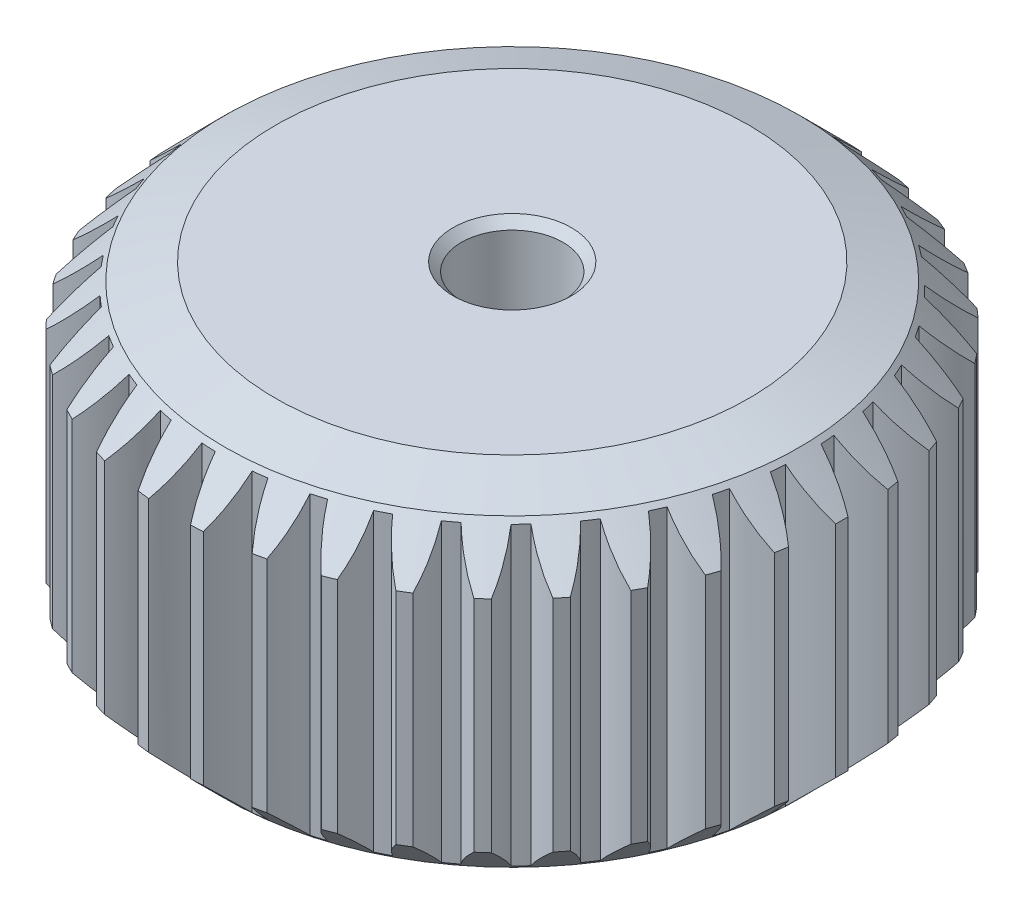
from build123d import *

# Parameters (mm, degrees)
EXTRUDE_1_DEPTH          = 20
EXTRUDE_1_2_DEPTH        = 20
EXTRUDE_1_3_DEPTH        = 20
EXTRUDE_1_4_DEPTH        = 20
EXTRUDE_1_5_DEPTH        = 20
EXTRUDE_1_6_DEPTH        = 20
EXTRUDE_1_7_DEPTH        = 20
EXTRUDE_1_8_DEPTH        = 20
EXTRUDE_1_9_DEPTH        = 20
EXTRUDE_1_10_DEPTH       = 20
EXTRUDE_1_11_DEPTH       = 20
EXTRUDE_1_12_DEPTH       = 20
EXTRUDE_1_13_DEPTH       = 20
EXTRUDE_1_14_DEPTH       = 20
EXTRUDE_1_15_DEPTH       = 20
EXTRUDE_1_16_DEPTH       = 20
EXTRUDE_1_17_DEPTH       = 20
EXTRUDE_1_18_DEPTH       = 20
EXTRUDE_1_19_DEPTH       = 20
EXTRUDE_1_20_DEPTH       = 20
EXTRUDE_1_21_DEPTH       = 20
EXTRUDE_1_22_DEPTH       = 20
EXTRUDE_1_23_DEPTH       = 20
EXTRUDE_1_24_DEPTH       = 20
EXTRUDE_1_25_DEPTH       = 20
EXTRUDE_1_26_DEPTH       = 20
EXTRUDE_1_27_DEPTH       = 20
EXTRUDE_1_28_DEPTH       = 20
EXTRUDE_1_29_DEPTH       = 20
EXTRUDE_1_30_DEPTH       = 20
EXTRUDE_1_31_DEPTH       = 20
EXTRUDE_1_32_DEPTH       = 20
EXTRUDE_1_33_DEPTH       = 20
EXTRUDE_1_34_DEPTH       = 20
EXTRUDE_1_35_DEPTH       = 20
EXTRUDE_1_36_DEPTH       = 20
EXTRUDE_1_37_DEPTH       = 20
SKETCH_2_R               = 17.25
EXTRUDE_2_DEPTH          = 20
SKETCH_3_R               = 3
CUT_EXTRUDE_1_DEPTH      = 1
CUT_EXTRUDE_1_DEPTH_BACK = 21
CHAMFER_1_SIZE           = 0.5


with BuildPart() as part:
    # 草图1 → 凸台-拉伸1 (new body)
    with BuildSketch(Plane(origin=(0, 0, 0), x_dir=(1, 0, 0), z_dir=(0, 1, 0))):
        with BuildLine():
            ThreePointArc((0.463179131, 19.494498329), (-0.032777448, 18.407729398), (-0.315632772, 17.247112105))
            ThreePointArc((-0.315632772, 17.247112105), (0.732110755, 17.234457167), (1.777152988, 17.158211657))
            ThreePointArc((1.777152988, 17.158211657), (1.593743876, 18.338635621), (1.19173843, 19.46354951))
            ThreePointArc((1.19173843, 19.46354951), (0.827603462, 19.482429841), (0.463179131, 19.494498329))
        make_face()
    extrude(amount=EXTRUDE_1_DEPTH)



with BuildPart() as body_2:
    # 草图1 → Extrude 1 2 (new body)
    with BuildSketch(Plane(origin=(0, 0, 0), x_dir=(1, 0, 0), z_dir=(0, 1, 0))):
        with BuildLine():
            ThreePointArc((2.603683412, 17.052370295), (3.634217407, 16.862827872), (4.651342106, 16.611066089))
            ThreePointArc((4.651342106, 16.611066089), (4.670063785, 17.805507019), (4.463952191, 18.982179296))
            ThreePointArc((4.463952191, 18.982179296), (4.108245765, 19.062327159), (3.751102931, 19.135810064))
            ThreePointArc((3.751102931, 19.135810064), (3.078615394, 18.148490384), (2.603683412, 17.052370295))
        make_face()
    extrude(amount=EXTRUDE_1_2_DEPTH)


with BuildPart() as body_3:
    # 草图1 → Extrude 1 3 (new body)
    with BuildSketch(Plane(origin=(0, 0, 0), x_dir=(1, 0, 0), z_dir=(0, 1, 0))):
        with BuildLine():
            ThreePointArc((5.448096364, 16.36706284), (6.431774242, 16.006085721), (7.391720579, 15.586050394))
            ThreePointArc((7.391720579, 15.586050394), (7.612034461, 16.760146399), (7.607746175, 17.954726345))
            ThreePointArc((7.607746175, 17.954726345), (7.270701317, 18.093836032), (6.931114328, 18.226619384))
            ThreePointArc((6.931114328, 18.226619384), (6.101442077, 17.367152344), (5.448096364, 16.36706284))
        make_face()
    extrude(amount=EXTRUDE_1_3_DEPTH)


with BuildPart() as body_4:
    # 草图1 → Extrude 1 4 (new body)
    with BuildSketch(Plane(origin=(0, 0, 0), x_dir=(1, 0, 0), z_dir=(0, 1, 0))):
        with BuildLine():
            ThreePointArc((8.135777504, 15.210904786), (9.044300641, 14.688877626), (9.91945271, 14.112652406))
            ThreePointArc((9.91945271, 14.112652406), (10.335020765, 15.232626883), (10.532679153, 16.410748608))
            ThreePointArc((10.532679153, 16.410748608), (10.223992029, 16.604818186), (9.911730186, 16.79308205))
            ThreePointArc((9.911730186, 16.79308205), (8.94874138, 16.086192952), (8.135777504, 15.210904786))
        make_face()
    extrude(amount=EXTRUDE_1_4_DEPTH)


with BuildPart() as body_5:
    # 草图1 → Extrude 1 5 (new body)
    with BuildSketch(Plane(origin=(0, 0, 0), x_dir=(1, 0, 0), z_dir=(0, 1, 0))):
        with BuildLine():
            ThreePointArc((10.589407138, 13.617156696), (11.396638978, 12.949097266), (12.161820246, 12.233259104))
            ThreePointArc((12.161820246, 12.233259104), (12.760687339, 13.266892425), (13.154606128, 14.394663511))
            ThreePointArc((13.154606128, 14.394663511), (12.883157106, 14.638109952), (12.607203612, 14.87643832))
            ThreePointArc((12.607203612, 14.87643832), (11.538601686, 14.342463076), (10.589407138, 13.617156696))
        make_face()
    extrude(amount=EXTRUDE_1_5_DEPTH)


with BuildPart() as body_6:
    # 草图1 → Extrude 1 6 (new body)
    with BuildSketch(Plane(origin=(0, 0, 0), x_dir=(1, 0, 0), z_dir=(0, 1, 0))):
        with BuildLine():
            ThreePointArc((12.738398808, 11.6316678), (13.421116762, 10.836794953), (14.054314357, 10.00193721))
            ThreePointArc((14.054314357, 10.00193721), (14.819252171, 10.919493627), (15.398099036, 11.964470154))
            ThreePointArc((15.398099036, 11.964470154), (15.171697209, 12.250289947), (14.939990745, 12.531826545))
            ThreePointArc((14.939990745, 12.531826545), (13.796517431, 12.186126651), (12.738398808, 11.6316678))
        make_face()
    extrude(amount=EXTRUDE_1_6_DEPTH)


with BuildPart() as body_7:
    # 草图1 → Extrude 1 7 (new body)
    with BuildSketch(Plane(origin=(0, 0, 0), x_dir=(1, 0, 0), z_dir=(0, 1, 0))):
        with BuildLine():
            ThreePointArc((14.520929937, 9.311556999), (15.059493452, 8.412737781), (15.542491433, 7.482877793))
            ThreePointArc((15.542491433, 7.482877793), (16.4514941, 8.257960878), (17.19861667, 9.190080774))
            ThreePointArc((17.19861667, 9.190080774), (17.023775207, 9.510051404), (16.842981545, 9.826696937))
            ThreePointArc((16.842981545, 9.826696937), (15.657532487, 9.679217549), (14.520929937, 9.311556999))
        make_face()
    extrude(amount=EXTRUDE_1_7_DEPTH)


with BuildPart() as body_8:
    # 草图1 → Extrude 1 8 (new body)
    with BuildSketch(Plane(origin=(0, 0, 0), x_dir=(1, 0, 0), z_dir=(0, 1, 0))):
        with BuildLine():
            ThreePointArc((15.885720351, 6.723569657), (16.264635934, 5.746661459), (16.583539328, 4.748549606))
            ThreePointArc((16.583539328, 4.748549606), (17.610456496, 5.35886163), (18.504361416, 6.151309503))
            ThreePointArc((18.504361416, 6.151309503), (18.386110186, 6.496225997), (18.261430431, 6.838871149))
            ThreePointArc((18.261430431, 6.838871149), (17.068108842, 6.893854982), (15.885720351, 6.723569657))
        make_face()
    extrude(amount=EXTRUDE_1_8_DEPTH)


with BuildPart() as body_9:
    # 草图1 → Extrude 1 9 (new body)
    with BuildSketch(Plane(origin=(0, 0, 0), x_dir=(1, 0, 0), z_dir=(0, 1, 0))):
        with BuildLine():
            ThreePointArc((16.793507513, 3.942157458), (17.001874453, 2.915264151), (17.14750899, 1.877614292))
            ThreePointArc((17.14750899, 1.877614292), (18.262798122, 2.30559769), (19.277769374, 2.935576257))
            ThreePointArc((19.277769374, 2.935576257), (19.219510252, 3.295515996), (19.154531213, 3.65430349))
            ThreePointArc((19.154531213, 3.65430349), (17.987666782, 3.910168758), (16.793507513, 3.942157458))
        make_face()
    extrude(amount=EXTRUDE_1_9_DEPTH)


with BuildPart() as body_10:
    # 草图1 → Extrude 1 10 (new body)
    with BuildSketch(Plane(origin=(0, 0, 0), x_dir=(1, 0, 0), z_dir=(0, 1, 0))):
        with BuildLine():
            ThreePointArc((17.218176039, 1.047336566), (17.25, 0), (17.218176039, -1.047336566))
            ThreePointArc((17.218176039, -1.047336566), (18.389752298, -0.813994098), (19.496591007, -0.364608173))
            ThreePointArc((19.496591007, -0.364608173), (19.5, 0), (19.496591007, 0.364608173))
            ThreePointArc((19.496591007, 0.364608173), (18.389752298, 0.813994098), (17.218176039, 1.047336566))
        make_face()
    extrude(amount=EXTRUDE_1_10_DEPTH)


with BuildPart() as body_11:
    # 草图1 → Extrude 1 11 (new body)
    with BuildSketch(Plane(origin=(0, 0, 0), x_dir=(1, 0, 0), z_dir=(0, 1, 0))):
        with BuildLine():
            ThreePointArc((17.14750899, -1.877614292), (17.001874453, -2.915264151), (16.793507513, -3.942157458))
            ThreePointArc((16.793507513, -3.942157458), (17.987666782, -3.910168758), (19.154531213, -3.65430349))
            ThreePointArc((19.154531213, -3.65430349), (19.219510252, -3.295515996), (19.277769374, -2.935576257))
            ThreePointArc((19.277769374, -2.935576257), (18.262798122, -2.30559769), (17.14750899, -1.877614292))
        make_face()
    extrude(amount=EXTRUDE_1_11_DEPTH)


with BuildPart() as body_12:
    # 草图1 → Extrude 1 12 (new body)
    with BuildSketch(Plane(origin=(0, 0, 0), x_dir=(1, 0, 0), z_dir=(0, 1, 0))):
        with BuildLine():
            ThreePointArc((16.583539328, -4.748549606), (16.264635934, -5.746661459), (15.885720351, -6.723569657))
            ThreePointArc((15.885720351, -6.723569657), (17.068108842, -6.893854982), (18.261430431, -6.838871149))
            ThreePointArc((18.261430431, -6.838871149), (18.386110186, -6.496225997), (18.504361416, -6.151309503))
            ThreePointArc((18.504361416, -6.151309503), (17.610456496, -5.35886163), (16.583539328, -4.748549606))
        make_face()
    extrude(amount=EXTRUDE_1_12_DEPTH)


with BuildPart() as body_13:
    # 草图1 → Extrude 1 13 (new body)
    with BuildSketch(Plane(origin=(0, 0, 0), x_dir=(1, 0, 0), z_dir=(0, 1, 0))):
        with BuildLine():
            ThreePointArc((15.542491433, -7.482877793), (15.059493452, -8.412737781), (14.520929937, -9.311556999))
            ThreePointArc((14.520929937, -9.311556999), (15.657532487, -9.679217549), (16.842981545, -9.826696937))
            ThreePointArc((16.842981545, -9.826696937), (17.023775207, -9.510051404), (17.19861667, -9.190080774))
            ThreePointArc((17.19861667, -9.190080774), (16.4514941, -8.257960878), (15.542491433, -7.482877793))
        make_face()
    extrude(amount=EXTRUDE_1_13_DEPTH)


with BuildPart() as body_14:
    # 草图1 → Extrude 1 14 (new body)
    with BuildSketch(Plane(origin=(0, 0, 0), x_dir=(1, 0, 0), z_dir=(0, 1, 0))):
        with BuildLine():
            ThreePointArc((14.054314357, -10.00193721), (13.421116762, -10.836794953), (12.738398808, -11.6316678))
            ThreePointArc((12.738398808, -11.6316678), (13.796517431, -12.186126651), (14.939990745, -12.531826545))
            ThreePointArc((14.939990745, -12.531826545), (15.171697209, -12.250289947), (15.398099036, -11.964470154))
            ThreePointArc((15.398099036, -11.964470154), (14.819252171, -10.919493627), (14.054314357, -10.00193721))
        make_face()
    extrude(amount=EXTRUDE_1_14_DEPTH)


with BuildPart() as body_15:
    # 草图1 → Extrude 1 15 (new body)
    with BuildSketch(Plane(origin=(0, 0, 0), x_dir=(1, 0, 0), z_dir=(0, 1, 0))):
        with BuildLine():
            ThreePointArc((12.161820246, -12.233259104), (11.396638978, -12.949097266), (10.589407138, -13.617156696))
            ThreePointArc((10.589407138, -13.617156696), (11.538601686, -14.342463076), (12.607203612, -14.87643832))
            ThreePointArc((12.607203612, -14.87643832), (12.883157106, -14.638109952), (13.154606128, -14.394663511))
            ThreePointArc((13.154606128, -14.394663511), (12.760687339, -13.266892425), (12.161820246, -12.233259104))
        make_face()
    extrude(amount=EXTRUDE_1_15_DEPTH)


with BuildPart() as body_16:
    # 草图1 → Extrude 1 16 (new body)
    with BuildSketch(Plane(origin=(0, 0, 0), x_dir=(1, 0, 0), z_dir=(0, 1, 0))):
        with BuildLine():
            ThreePointArc((9.91945271, -14.112652406), (9.044300641, -14.688877626), (8.135777504, -15.210904786))
            ThreePointArc((8.135777504, -15.210904786), (8.94874138, -16.086192952), (9.911730186, -16.79308205))
            ThreePointArc((9.911730186, -16.79308205), (10.223992029, -16.604818186), (10.532679153, -16.410748608))
            ThreePointArc((10.532679153, -16.410748608), (10.335020765, -15.232626883), (9.91945271, -14.112652406))
        make_face()
    extrude(amount=EXTRUDE_1_16_DEPTH)


with BuildPart() as body_17:
    # 草图1 → Extrude 1 17 (new body)
    with BuildSketch(Plane(origin=(0, 0, 0), x_dir=(1, 0, 0), z_dir=(0, 1, 0))):
        with BuildLine():
            ThreePointArc((7.391720579, -15.586050394), (6.431774242, -16.006085721), (5.448096364, -16.36706284))
            ThreePointArc((5.448096364, -16.36706284), (6.101442077, -17.367152344), (6.931114328, -18.226619384))
            ThreePointArc((6.931114328, -18.226619384), (7.270701317, -18.093836032), (7.607746175, -17.954726345))
            ThreePointArc((7.607746175, -17.954726345), (7.612034461, -16.760146399), (7.391720579, -15.586050394))
        make_face()
    extrude(amount=EXTRUDE_1_17_DEPTH)


with BuildPart() as body_18:
    # 草图1 → Extrude 1 18 (new body)
    with BuildSketch(Plane(origin=(0, 0, 0), x_dir=(1, 0, 0), z_dir=(0, 1, 0))):
        with BuildLine():
            ThreePointArc((4.651342106, -16.611066089), (3.634217407, -16.862827872), (2.603683412, -17.052370295))
            ThreePointArc((2.603683412, -17.052370295), (3.078615394, -18.148490384), (3.751102931, -19.135810064))
            ThreePointArc((3.751102931, -19.135810064), (4.108245765, -19.062327159), (4.463952191, -18.982179296))
            ThreePointArc((4.463952191, -18.982179296), (4.670063785, -17.805507019), (4.651342106, -16.611066089))
        make_face()
    extrude(amount=EXTRUDE_1_18_DEPTH)


with BuildPart() as body_19:
    # 草图1 → Extrude 1 19 (new body)
    with BuildSketch(Plane(origin=(0, 0, 0), x_dir=(1, 0, 0), z_dir=(0, 1, 0))):
        with BuildLine():
            ThreePointArc((1.777152988, -17.158211657), (0.732110755, -17.234457167), (-0.315632772, -17.247112105))
            ThreePointArc((-0.315632772, -17.247112105), (-0.032777448, -18.407729398), (0.463179131, -19.494498329))
            ThreePointArc((0.463179131, -19.494498329), (0.827603462, -19.482429841), (1.19173843, -19.46354951))
            ThreePointArc((1.19173843, -19.46354951), (1.593743876, -18.338635621), (1.777152988, -17.158211657))
        make_face()
    extrude(amount=EXTRUDE_1_19_DEPTH)


with BuildPart() as body_20:
    # 草图1 → Extrude 1 20 (new body)
    with BuildSketch(Plane(origin=(0, 0, 0), x_dir=(1, 0, 0), z_dir=(0, 1, 0))):
        with BuildLine():
            ThreePointArc((-1.148161585, -17.211746715), (-2.191057391, -17.110282508), (-3.225868776, -16.945685901))
            ThreePointArc((-3.225868776, -16.945685901), (-3.143227343, -18.137411553), (-2.838069488, -19.29236537))
            ThreePointArc((-2.838069488, -19.29236537), (-2.476847485, -19.342058488), (-2.114759476, -19.384988841))
            ThreePointArc((-2.114759476, -19.384988841), (-1.528425142, -18.344195064), (-1.148161585, -17.211746715))
        make_face()
    extrude(amount=EXTRUDE_1_20_DEPTH)


with BuildPart() as body_21:
    # 草图1 → Extrude 1 21 (new body)
    with BuildSketch(Plane(origin=(0, 0, 0), x_dir=(1, 0, 0), z_dir=(0, 1, 0))):
        with BuildLine():
            ThreePointArc((-4.04044564, -16.770131157), (-5.051192805, -16.493876174), (-6.043302409, -16.156763166))
            ThreePointArc((-6.043302409, -16.156763166), (-6.16325231, -17.3453134), (-6.057672016, -18.535226186))
            ThreePointArc((-6.057672016, -18.535226186), (-5.71004404, -18.645251327), (-5.360419602, -18.748757337))
            ThreePointArc((-5.360419602, -18.748757337), (-4.606624152, -17.822025415), (-4.04044564, -16.770131157))
        make_face()
    extrude(amount=EXTRUDE_1_21_DEPTH)


with BuildPart() as body_22:
    # 草图1 → Extrude 1 22 (new body)
    with BuildSketch(Plane(origin=(0, 0, 0), x_dir=(1, 0, 0), z_dir=(0, 1, 0))):
        with BuildLine():
            ThreePointArc((-6.81649343, -15.84606946), (-7.766014598, -15.402971053), (-8.686881234, -14.903039772))
            ThreePointArc((-8.686881234, -14.903039772), (-9.00597173, -16.05422216), (-9.103006348, -17.244862291))
            ThreePointArc((-9.103006348, -17.244862291), (-8.778973024, -17.412054234), (-8.451870216, -17.573158221))
            ThreePointArc((-8.451870216, -17.573158221), (-7.552298972, -16.787148543), (-6.81649343, -15.84606946))
        make_face()
    extrude(amount=EXTRUDE_1_22_DEPTH)


with BuildPart() as body_23:
    # 草图1 → Extrude 1 23 (new body)
    with BuildSketch(Plane(origin=(0, 0, 0), x_dir=(1, 0, 0), z_dir=(0, 1, 0))):
        with BuildLine():
            ThreePointArc((-9.396443115, -14.466145195), (-10.257422291, -13.868950499), (-11.080554302, -13.220583057))
            ThreePointArc((-11.080554302, -13.220583057), (-11.589605739, -14.301280179), (-11.886463762, -15.458395105))
            ThreePointArc((-11.886463762, -15.458395105), (-11.595346938, -15.677944042), (-11.300175912, -15.892011338))
            ThreePointArc((-11.300175912, -15.892011338), (-10.280707901, -15.269335972), (-9.396443115, -14.466145195))
        make_face()
    extrude(amount=EXTRUDE_1_23_DEPTH)


with BuildPart() as body_24:
    # 草图1 → Extrude 1 24 (new body)
    with BuildSketch(Plane(origin=(0, 0, 0), x_dir=(1, 0, 0), z_dir=(0, 1, 0))):
        with BuildLine():
            ThreePointArc((-11.706074239, -12.670056271), (-12.453742621, -11.93594549), (-13.155459997, -11.157794238))
            ThreePointArc((-13.155459997, -11.157794238), (-13.839827893, -12.136916406), (-14.327969256, -13.227218037))
            ThreePointArc((-14.327969256, -13.227218037), (-14.078143832, -13.492807945), (-13.823396121, -13.753680223))
            ThreePointArc((-13.823396121, -13.753680223), (-12.713359582, -13.312252405), (-11.706074239, -12.670056271))
        make_face()
    extrude(amount=EXTRUDE_1_24_DEPTH)


with BuildPart() as body_25:
    # 草图1 → Extrude 1 25 (new body)
    with BuildSketch(Plane(origin=(0, 0, 0), x_dir=(1, 0, 0), z_dir=(0, 1, 0))):
        with BuildLine():
            ThreePointArc((-13.678942921, -10.509472896), (-14.291791449, -9.659565061), (-14.85190706, -8.774015994))
            ThreePointArc((-14.85190706, -8.774015994), (-15.691903397, -9.623395645), (-16.35728516, -10.61551799))
            ThreePointArc((-16.35728516, -10.61551799), (-16.15593816, -10.91950833), (-15.948942392, -11.219680769))
            ThreePointArc((-15.948942392, -11.219680769), (-14.780271055, -10.972199575), (-13.678942921, -10.509472896))
        make_face()
    extrude(amount=EXTRUDE_1_25_DEPTH)


with BuildPart() as body_26:
    # 草图1 → Extrude 1 26 (new body)
    with BuildSketch(Plane(origin=(0, 0, 0), x_dir=(1, 0, 0), z_dir=(0, 1, 0))):
        with BuildLine():
            ThreePointArc((-15.258293321, -8.046551121), (-15.718691459, -7.105296532), (-16.121091798, -6.137825285))
            ThreePointArc((-16.121091798, -6.137825285), (-17.09255141, -6.833027313), (-17.916031752, -7.698428817))
            ThreePointArc((-17.916031752, -7.698428817), (-17.768955563, -8.032074341), (-17.615666629, -8.362911528))
            ThreePointArc((-17.615666629, -8.362911528), (-16.42198104, -8.31649654), (-15.258293321, -8.046551121))
        make_face()
    extrude(amount=EXTRUDE_1_26_DEPTH)


with BuildPart() as body_27:
    # 草图1 → Extrude 1 27 (new body)
    with BuildSketch(Plane(origin=(0, 0, 0), x_dir=(1, 0, 0), z_dir=(0, 1, 0))):
        with BuildLine():
            ThreePointArc((-16.398690402, -5.35214472), (-16.693393335, -4.346621559), (-16.926502077, -3.325060518))
            ThreePointArc((-16.926502077, -3.325060518), (-18.001477839, -3.846085226), (-18.959366731, -4.559869863))
            ThreePointArc((-18.959366731, -4.559869863), (-18.870792465, -4.913572197), (-18.775620209, -5.265556548))
            ThreePointArc((-18.775620209, -5.265556548), (-17.59126053, -5.421543041), (-16.398690402, -5.35214472))
        make_face()
    extrude(amount=EXTRUDE_1_27_DEPTH)


with BuildPart() as body_28:
    # 草图1 → Extrude 1 28 (new body)
    with BuildSketch(Plane(origin=(0, 0, 0), x_dir=(1, 0, 0), z_dir=(0, 1, 0))):
        with BuildLine():
            ThreePointArc((-17.067327017, -2.503766861), (-17.187856677, -1.462902197), (-17.244967708, -0.416639813))
            ThreePointArc((-17.244967708, -0.416639813), (-18.392534526, -0.748498269), (-19.457275247, -1.290131756))
            ThreePointArc((-19.457275247, -1.290131756), (-19.429751027, -1.653715527), (-19.395433381, -2.016721093))
            ThreePointArc((-19.395433381, -2.016721093), (-18.254471482, -2.37062162), (-17.067327017, -2.503766861))
        make_face()
    extrude(amount=EXTRUDE_1_28_DEPTH)


with BuildPart() as body_29:
    # 草图1 → Extrude 1 29 (new body)
    with BuildSketch(Plane(origin=(0, 0, 0), x_dir=(1, 0, 0), z_dir=(0, 1, 0))):
        with BuildLine():
            ThreePointArc((-17.244967708, 0.416639813), (-17.187856677, 1.462902197), (-17.067327017, 2.503766861))
            ThreePointArc((-17.067327017, 2.503766861), (-18.254471482, 2.37062162), (-19.395433381, 2.016721093))
            ThreePointArc((-19.395433381, 2.016721093), (-19.429751027, 1.653715527), (-19.457275247, 1.290131756))
            ThreePointArc((-19.457275247, 1.290131756), (-18.392534526, 0.748498269), (-17.244967708, 0.416639813))
        make_face()
    extrude(amount=EXTRUDE_1_29_DEPTH)


with BuildPart() as body_30:
    # 草图1 → Extrude 1 30 (new body)
    with BuildSketch(Plane(origin=(0, 0, 0), x_dir=(1, 0, 0), z_dir=(0, 1, 0))):
        with BuildLine():
            ThreePointArc((-16.926502077, 3.325060518), (-16.693393335, 4.346621559), (-16.398690402, 5.35214472))
            ThreePointArc((-16.398690402, 5.35214472), (-17.59126053, 5.421543041), (-18.775620209, 5.265556548))
            ThreePointArc((-18.775620209, 5.265556548), (-18.870792465, 4.913572197), (-18.959366731, 4.559869863))
            ThreePointArc((-18.959366731, 4.559869863), (-18.001477839, 3.846085226), (-16.926502077, 3.325060518))
        make_face()
    extrude(amount=EXTRUDE_1_30_DEPTH)


with BuildPart() as body_31:
    # 草图1 → Extrude 1 31 (new body)
    with BuildSketch(Plane(origin=(0, 0, 0), x_dir=(1, 0, 0), z_dir=(0, 1, 0))):
        with BuildLine():
            ThreePointArc((-16.121091798, 6.137825285), (-15.718691459, 7.105296532), (-15.258293321, 8.046551121))
            ThreePointArc((-15.258293321, 8.046551121), (-16.42198104, 8.31649654), (-17.615666629, 8.362911528))
            ThreePointArc((-17.615666629, 8.362911528), (-17.768955563, 8.032074341), (-17.916031752, 7.698428817))
            ThreePointArc((-17.916031752, 7.698428817), (-17.09255141, 6.833027313), (-16.121091798, 6.137825285))
        make_face()
    extrude(amount=EXTRUDE_1_31_DEPTH)


with BuildPart() as body_32:
    # 草图1 → Extrude 1 32 (new body)
    with BuildSketch(Plane(origin=(0, 0, 0), x_dir=(1, 0, 0), z_dir=(0, 1, 0))):
        with BuildLine():
            ThreePointArc((-14.85190706, 8.774015994), (-14.291791449, 9.659565061), (-13.678942921, 10.509472896))
            ThreePointArc((-13.678942921, 10.509472896), (-14.780271055, 10.972199575), (-15.948942392, 11.219680769))
            ThreePointArc((-15.948942392, 11.219680769), (-16.15593816, 10.91950833), (-16.35728516, 10.61551799))
            ThreePointArc((-16.35728516, 10.61551799), (-15.691903397, 9.623395645), (-14.85190706, 8.774015994))
        make_face()
    extrude(amount=EXTRUDE_1_32_DEPTH)


with BuildPart() as body_33:
    # 草图1 → Extrude 1 33 (new body)
    with BuildSketch(Plane(origin=(0, 0, 0), x_dir=(1, 0, 0), z_dir=(0, 1, 0))):
        with BuildLine():
            ThreePointArc((-13.155459997, 11.157794238), (-12.453742621, 11.93594549), (-11.706074239, 12.670056271))
            ThreePointArc((-11.706074239, 12.670056271), (-12.713359582, 13.312252405), (-13.823396121, 13.753680223))
            ThreePointArc((-13.823396121, 13.753680223), (-14.078143832, 13.492807945), (-14.327969256, 13.227218037))
            ThreePointArc((-14.327969256, 13.227218037), (-13.839827893, 12.136916406), (-13.155459997, 11.157794238))
        make_face()
    extrude(amount=EXTRUDE_1_33_DEPTH)


with BuildPart() as body_34:
    # 草图1 → Extrude 1 34 (new body)
    with BuildSketch(Plane(origin=(0, 0, 0), x_dir=(1, 0, 0), z_dir=(0, 1, 0))):
        with BuildLine():
            ThreePointArc((-11.080554302, 13.220583057), (-10.257422291, 13.868950499), (-9.396443115, 14.466145195))
            ThreePointArc((-9.396443115, 14.466145195), (-10.280707901, 15.269335972), (-11.300175912, 15.892011338))
            ThreePointArc((-11.300175912, 15.892011338), (-11.595346938, 15.677944042), (-11.886463762, 15.458395105))
            ThreePointArc((-11.886463762, 15.458395105), (-11.589605739, 14.301280179), (-11.080554302, 13.220583057))
        make_face()
    extrude(amount=EXTRUDE_1_34_DEPTH)


with BuildPart() as body_35:
    # 草图1 → Extrude 1 35 (new body)
    with BuildSketch(Plane(origin=(0, 0, 0), x_dir=(1, 0, 0), z_dir=(0, 1, 0))):
        with BuildLine():
            ThreePointArc((-8.686881234, 14.903039772), (-7.766014598, 15.402971053), (-6.81649343, 15.84606946))
            ThreePointArc((-6.81649343, 15.84606946), (-7.552298972, 16.787148543), (-8.451870216, 17.573158221))
            ThreePointArc((-8.451870216, 17.573158221), (-8.778973024, 17.412054234), (-9.103006348, 17.244862291))
            ThreePointArc((-9.103006348, 17.244862291), (-9.00597173, 16.05422216), (-8.686881234, 14.903039772))
        make_face()
    extrude(amount=EXTRUDE_1_35_DEPTH)


with BuildPart() as body_36:
    # 草图1 → Extrude 1 36 (new body)
    with BuildSketch(Plane(origin=(0, 0, 0), x_dir=(1, 0, 0), z_dir=(0, 1, 0))):
        with BuildLine():
            ThreePointArc((-6.043302409, 16.156763166), (-5.051192805, 16.493876174), (-4.04044564, 16.770131157))
            ThreePointArc((-4.04044564, 16.770131157), (-4.606624152, 17.822025415), (-5.360419602, 18.748757337))
            ThreePointArc((-5.360419602, 18.748757337), (-5.71004404, 18.645251327), (-6.057672016, 18.535226186))
            ThreePointArc((-6.057672016, 18.535226186), (-6.16325231, 17.3453134), (-6.043302409, 16.156763166))
        make_face()
    extrude(amount=EXTRUDE_1_36_DEPTH)


with BuildPart() as body_37:
    # 草图1 → Extrude 1 37 (new body)
    with BuildSketch(Plane(origin=(0, 0, 0), x_dir=(1, 0, 0), z_dir=(0, 1, 0))):
        with BuildLine():
            ThreePointArc((-3.225868776, 16.945685901), (-2.191057391, 17.110282508), (-1.148161585, 17.211746715))
            ThreePointArc((-1.148161585, 17.211746715), (-1.528425142, 18.344195064), (-2.114759476, 19.384988841))
            ThreePointArc((-2.114759476, 19.384988841), (-2.476847485, 19.342058488), (-2.838069488, 19.29236537))
            ThreePointArc((-2.838069488, 19.29236537), (-3.143227343, 18.137411553), (-3.225868776, 16.945685901))
        make_face()
    extrude(amount=EXTRUDE_1_37_DEPTH)


with BuildPart() as part_1:
    add(part.part)

    add(body_2.part)  # 凸台-拉伸2 merges body 2

    add(body_3.part)  # 凸台-拉伸2 merges body 3

    add(body_4.part)  # 凸台-拉伸2 merges body 4

    add(body_5.part)  # 凸台-拉伸2 merges body 5

    add(body_6.part)  # 凸台-拉伸2 merges body 6

    add(body_7.part)  # 凸台-拉伸2 merges body 7

    add(body_8.part)  # 凸台-拉伸2 merges body 8

    add(body_9.part)  # 凸台-拉伸2 merges body 9

    add(body_10.part)  # 凸台-拉伸2 merges body 10

    add(body_11.part)  # 凸台-拉伸2 merges body 11

    add(body_12.part)  # 凸台-拉伸2 merges body 12

    add(body_13.part)  # 凸台-拉伸2 merges body 13

    add(body_14.part)  # 凸台-拉伸2 merges body 14

    add(body_15.part)  # 凸台-拉伸2 merges body 15

    add(body_16.part)  # 凸台-拉伸2 merges body 16

    add(body_17.part)  # 凸台-拉伸2 merges body 17

    add(body_18.part)  # 凸台-拉伸2 merges body 18

    add(body_19.part)  # 凸台-拉伸2 merges body 19

    add(body_20.part)  # 凸台-拉伸2 merges body 20

    add(body_21.part)  # 凸台-拉伸2 merges body 21

    add(body_22.part)  # 凸台-拉伸2 merges body 22

    add(body_23.part)  # 凸台-拉伸2 merges body 23

    add(body_24.part)  # 凸台-拉伸2 merges body 24

    add(body_25.part)  # 凸台-拉伸2 merges body 25

    add(body_26.part)  # 凸台-拉伸2 merges body 26

    add(body_27.part)  # 凸台-拉伸2 merges body 27

    add(body_28.part)  # 凸台-拉伸2 merges body 28

    add(body_29.part)  # 凸台-拉伸2 merges body 29

    add(body_30.part)  # 凸台-拉伸2 merges body 30

    add(body_31.part)  # 凸台-拉伸2 merges body 31

    add(body_32.part)  # 凸台-拉伸2 merges body 32

    add(body_33.part)  # 凸台-拉伸2 merges body 33

    add(body_34.part)  # 凸台-拉伸2 merges body 34

    add(body_35.part)  # 凸台-拉伸2 merges body 35

    add(body_36.part)  # 凸台-拉伸2 merges body 36

    add(body_37.part)  # 凸台-拉伸2 merges body 37
    # 草图2 → 凸台-拉伸2 (add)
    with BuildSketch(Plane(origin=(0, 0, 0), x_dir=(1, 0, 0), z_dir=(0, 1, 0))):
        Circle(SKETCH_2_R)
    extrude(amount=EXTRUDE_2_DEPTH)

    # 草图3 → 切除-拉伸1 (cut, two sides)
    with BuildSketch(Plane(origin=(0, 20, 0), x_dir=(1, 0, 0), z_dir=(0, 1, 0))) as cut_extrude_1_sk:
        Circle(SKETCH_3_R)
    extrude(amount=CUT_EXTRUDE_1_DEPTH, mode=Mode.SUBTRACT)
    extrude(cut_extrude_1_sk.sketch, amount=-CUT_EXTRUDE_1_DEPTH_BACK, mode=Mode.SUBTRACT)

    # 草图4 → 切除-旋转1 (revolve, cut)
    with BuildSketch(Plane(origin=(0, 0, 0), x_dir=(0, 0, -1), z_dir=(1, 0, 0))):
        Polygon((14, 20), (20, 20), (20, 18), align=None)
        Polygon((20, 2), (14, 0), (20, 0), align=None)
    revolve(axis=Axis((0, 0, 0), (0, 1, 0)), mode=Mode.SUBTRACT)

    # 草图5 → 切除-旋转2 (revolve, cut)
    with BuildSketch(Plane(origin=(0, 0, 0), x_dir=(0, 0, -1), z_dir=(1, 0, 0))):
        Polygon((16, 20), (19.5, 16.5), (19.5, 20), align=None)
        Polygon((19.5, 3.5), (19.5, 0), (16, 0), align=None)
    revolve(axis=Axis((0, 0, 0), (0, 1, 0)), mode=Mode.SUBTRACT)

    # 倒角1
    chamfer_1_edges = [part_1.edges().sort_by_distance(p)[0] for p in [
        (-3, 0, 0),
        (-3, 20, 0),
    ]]
    chamfer(chamfer_1_edges, length=CHAMFER_1_SIZE)


solid = part_1.part
